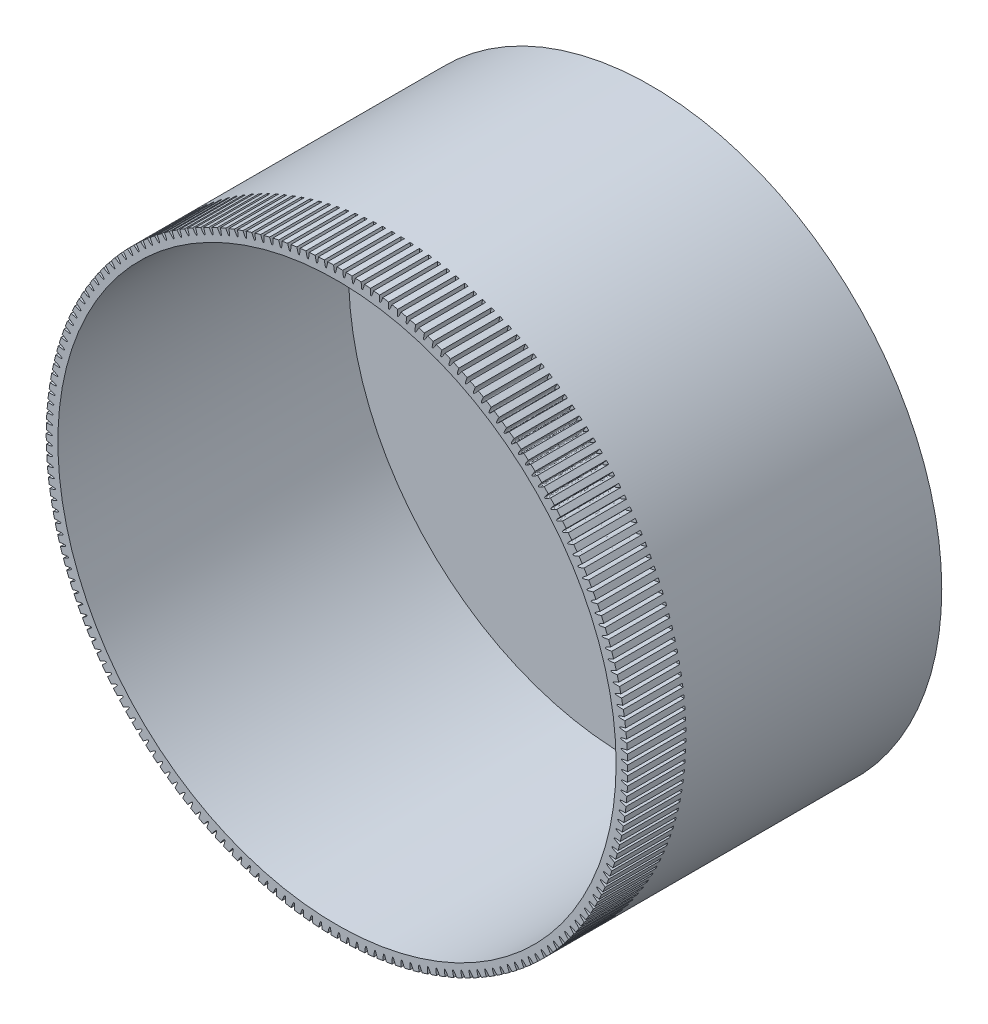
from build123d import *

# Parameters (mm, degrees)
SKETCH_1_R               = 25
EXTRUDE_1_DEPTH          = 27
SKETCH_2_R               = 24
CUT_EXTRUDE_1_DEPTH      = 25
SKETCH_3_R               = 5
CUT_EXTRUDE_2_DEPTH      = 25
CUT_EXTRUDE_5_DEPTH      = 5
PATTERN_CIRCULAR_1_COUNT = 198


with BuildPart() as part:
    # 草图1 → 凸台-拉伸1 (new body)
    with BuildSketch(Plane.XY):
        Circle(SKETCH_1_R)
    extrude(amount=EXTRUDE_1_DEPTH)

    # 草图2 → 切除-拉伸1 (cut)
    with BuildSketch(Plane.XY.offset(27)):
        Circle(SKETCH_2_R)
    extrude(amount=-CUT_EXTRUDE_1_DEPTH, mode=Mode.SUBTRACT)

    # 草图3 → 切除-拉伸2 (cut)
    with BuildSketch(Plane.XY.offset(2)):
        Circle(SKETCH_3_R)
    extrude(amount=-CUT_EXTRUDE_2_DEPTH, mode=Mode.SUBTRACT)

    # 草图4 → 切除-拉伸5 (cut)
    with BuildSketch(Plane.XY.offset(27)):
        with BuildLine():
            Line((-25.087613658, 3.65096297), (-25.148791276, 3.283897264))
            add(Edge.make_bspline(
                [(-25.087613658, 3.65096297), (-23.384712287, 3.162248335), (-25.148791276, 3.283897264)],
                knots=[0, 0, 0, 1, 1, 1], degree=2))
        make_face()
    cut_extrude_5 = extrude(amount=-CUT_EXTRUDE_5_DEPTH, mode=Mode.SUBTRACT)

    # 阵列(圆周)1: 切除-拉伸5 ×198 about axis
    pattern_circular_1_axis = Axis((0, 0, 27), (0, 0, -1))
    for i in range(1, PATTERN_CIRCULAR_1_COUNT):
        add(cut_extrude_5.rotate(pattern_circular_1_axis, i * 360 / PATTERN_CIRCULAR_1_COUNT), mode=Mode.SUBTRACT)


solid = part.part
